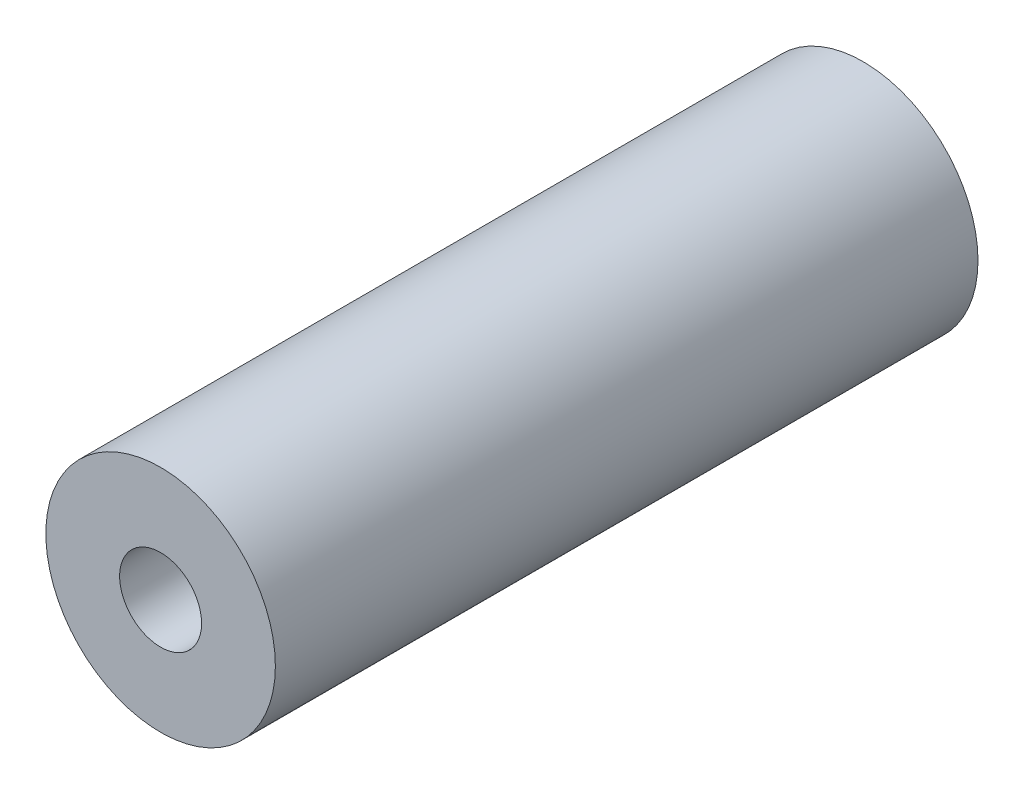
from build123d import *

# Parameters (mm, degrees)
SKETCH1_R           = 4.9
SKETCH1_R_2         = 1.75
BOSS_EXTRUDE1_DEPTH = 30


with BuildPart() as part:
    # Sketch1 → Boss-Extrude1 (new body)
    with BuildSketch(Plane.XY):
        Circle(SKETCH1_R)
        Circle(SKETCH1_R_2, mode=Mode.SUBTRACT)
    extrude(amount=BOSS_EXTRUDE1_DEPTH)


solid = part.part
